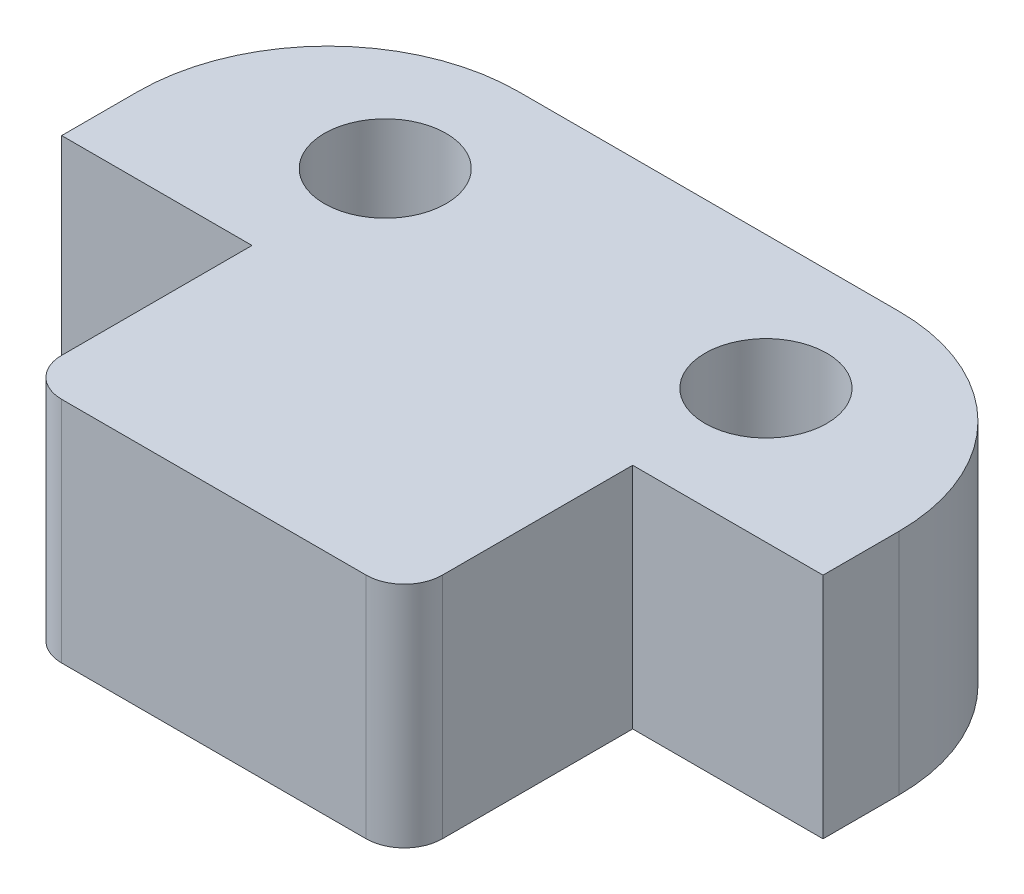
from build123d import *

# Parameters (mm, degrees)
SKETCH1_W             = 20
SKETCH1_H             = 7
BOSS_EXTRUDE1_DEPTH   = 6
SKETCH234_W           = 10
SKETCH234_H           = 6
BOSS_EXTRUDE234_DEPTH = 6
FILLET134_R           = 1
M3_CLEARANCE_HOLE1_D  = 3.2
FILLET135_R           = 5


with BuildPart() as part:
    # Sketch1 → Boss-Extrude1 (new body)
    with BuildSketch(Plane(origin=(0, 0, 0), x_dir=(1, 0, 0), z_dir=(0, 1, 0))):
        Rectangle(SKETCH1_W, SKETCH1_H)
    extrude(amount=BOSS_EXTRUDE1_DEPTH)

    # Sketch234 → Boss-Extrude234 (add)
    with BuildSketch(Plane(origin=(-0.767778608, 0, 3.5), x_dir=(1, 0, 0), z_dir=(0, 0, 1))):
        with Locations((0.767778608, 3)):
            Rectangle(SKETCH234_W, SKETCH234_H)
    extrude(amount=BOSS_EXTRUDE234_DEPTH)

    # Fillet134
    fillet134_edges = [part.edges().sort_by_distance(p)[0] for p in [
        (-5, 3, 9.5),
        (5, 3, 9.5),
    ]]
    fillet(fillet134_edges, radius=FILLET134_R)

    # M3 Clearance Hole1 (through all)
    with Locations(Plane(origin=(0, 0, 0), x_dir=(-1, 0, 0), z_dir=(0, -1, 0))):
        with Locations((5, 0), (-5, 0)):
            Hole(M3_CLEARANCE_HOLE1_D / 2)

    # Fillet135
    fillet135_edges = [part.edges().sort_by_distance(p)[0] for p in [
        (-10, 3, -3.5),
        (10, 3, -3.5),
    ]]
    fillet(fillet135_edges, radius=FILLET135_R)


solid = part.part
